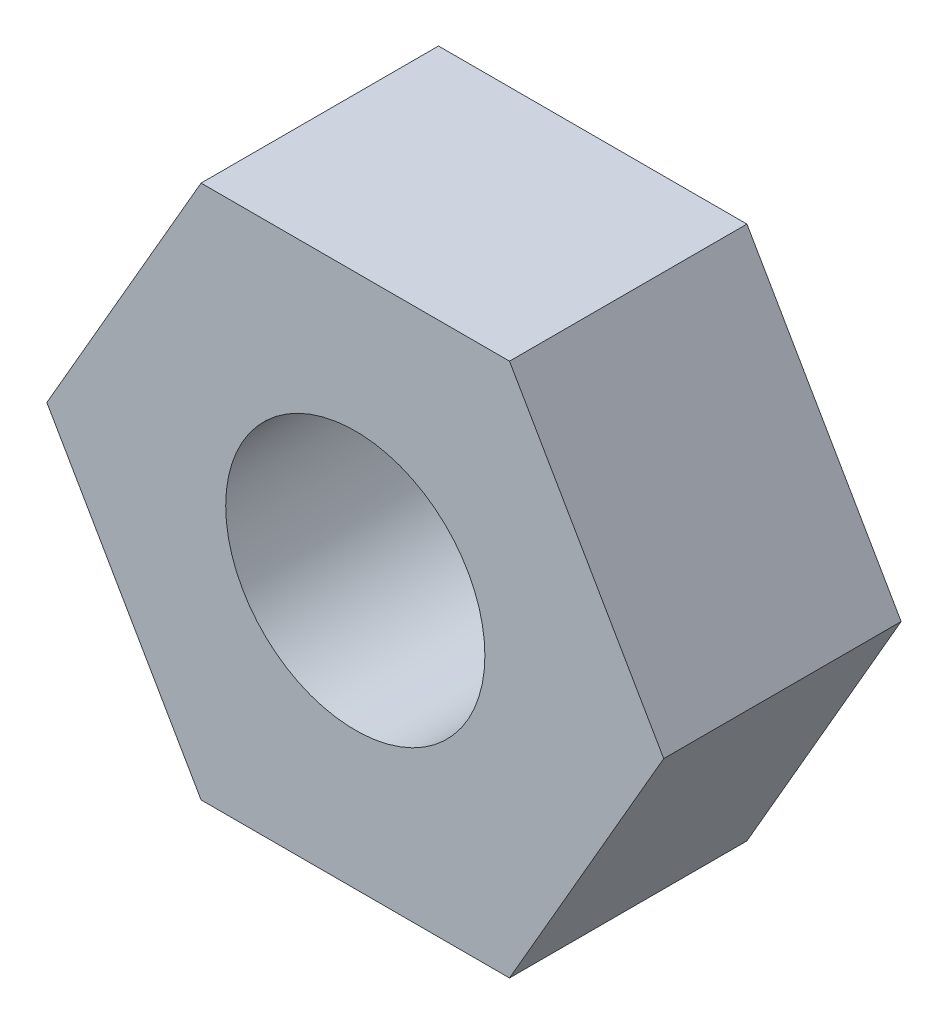
from build123d import *

# Parameters (mm, degrees)
SKETCH1_R           = 1.6637
BOSS_EXTRUDE1_DEPTH = 3.048


with BuildPart() as part:
    # Sketch1 → Boss-Extrude1 (new body)
    with BuildSketch(Plane.XY):
        Polygon((3.959468146, 0), (1.979734073, 3.429), (-1.979734073, 3.429), (-3.959468146, 0), (-1.979734073, -3.429), (1.979734073, -3.429), align=None)
        Circle(SKETCH1_R, mode=Mode.SUBTRACT)
    extrude(amount=BOSS_EXTRUDE1_DEPTH)


solid = part.part
